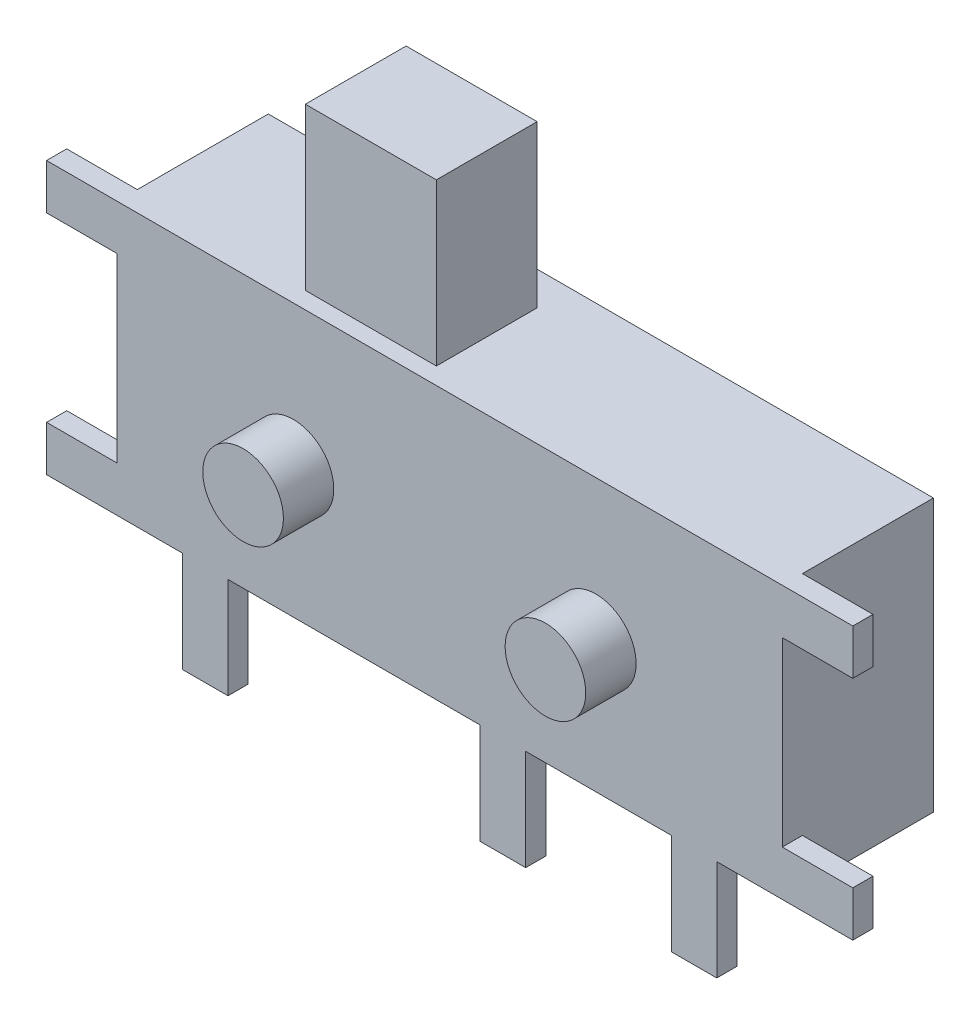
from build123d import *

# Parameters (mm, degrees)
SKETCH_1_W         = 6.6
SKETCH_1_H         = 2.7
EXTRUDE_1_DEPTH    = 1.5
SKETCH_2_W         = 0.7
SKETCH_2_H         = 0.45
EXTRUDE_664_DEPTH  = 0.2
SKETCH_3_W         = 0.45
SKETCH_3_H         = 1
SKETCH_3_W_2       = 0.45404522
EXTRUDE_1058_DEPTH = 0.2
SKETCH_4_W         = 1.3
SKETCH_4_H         = 1
EXTRUDE_4_DEPTH    = 1.6
SKETCH_5_R         = 0.4
EXTRUDE_5_DEPTH    = 0.5


with BuildPart() as part:
    # 草图1 → 凸台-拉伸1 (new body)
    with BuildSketch(Plane.XY):
        Rectangle(SKETCH_1_W, SKETCH_1_H)
    extrude(amount=-EXTRUDE_1_DEPTH)

    # 草图2 → Extrude 664 (add)
    with BuildSketch(Plane.XY):
        with Locations((-3.65, 1.125)):
            Rectangle(SKETCH_2_W, SKETCH_2_H)
        with Locations((3.65, 1.125)):
            Rectangle(SKETCH_2_W, SKETCH_2_H)
        with Locations((3.65, -1.125)):
            Rectangle(SKETCH_2_W, SKETCH_2_H)
        with Locations((-3.65, -1.125)):
            Rectangle(SKETCH_2_W, SKETCH_2_H)
    extrude(amount=-EXTRUDE_664_DEPTH)

    # 草图3 → Extrude 1058 (add)
    with BuildSketch(Plane.XY):
        with Locations((2.425, -1.85)):
            Rectangle(SKETCH_3_W, SKETCH_3_H)
        with Locations((-2.425, -1.85)):
            Rectangle(SKETCH_3_W, SKETCH_3_H)
        with Locations((0.52702261, -1.85)):
            Rectangle(SKETCH_3_W_2, SKETCH_3_H)
    extrude(amount=-EXTRUDE_1058_DEPTH)

    # 草图4 → 凸台-拉伸4 (add)
    with BuildSketch(Plane(origin=(0, 1.35, 0), x_dir=(1, 0, 0), z_dir=(0, 1, 0))):
        with Locations((-0.95, 0.667693313)):
            Rectangle(SKETCH_4_W, SKETCH_4_H)
    extrude(amount=EXTRUDE_4_DEPTH)

    # 草图5 → 凸台-拉伸5 (add)
    with BuildSketch(Plane.XY):
        with Locations((1.45, -0.05)):
            Circle(SKETCH_5_R)
        with Locations((-1.55, -0.05)):
            Circle(SKETCH_5_R)
    extrude(amount=EXTRUDE_5_DEPTH)


solid = part.part
